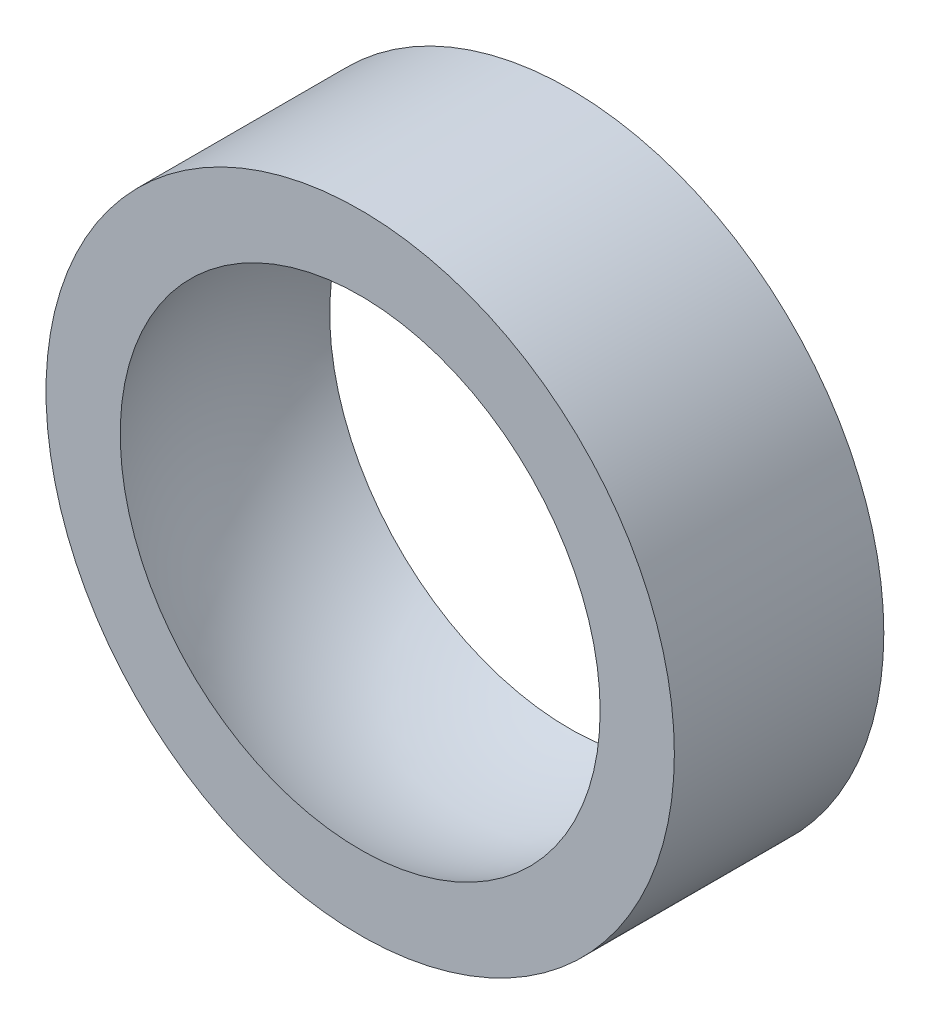
from build123d import *

# Parameters (mm, degrees)
DIA_CYLINDRE_R = 15
CYLINDRE_DEPTH = 5


with BuildPart() as part:
    # Dia cylindre → Cylindre (new body, symmetric)
    with BuildSketch(Plane.XY):
        Circle(DIA_CYLINDRE_R)
    extrude(amount=CYLINDRE_DEPTH, both=True)

    # Esquisse sphère → Sphère intérieure (revolve, cut)
    with BuildSketch(Plane.XY):
        with BuildLine():
            Line((0, 12.5), (0, -12.5))
            ThreePointArc((0, -12.5), (12.5, 0), (0, 12.5))
        make_face()
    revolve(axis=Axis((0, 20, 0), (0, -1, 0)), mode=Mode.SUBTRACT)


solid = part.part
